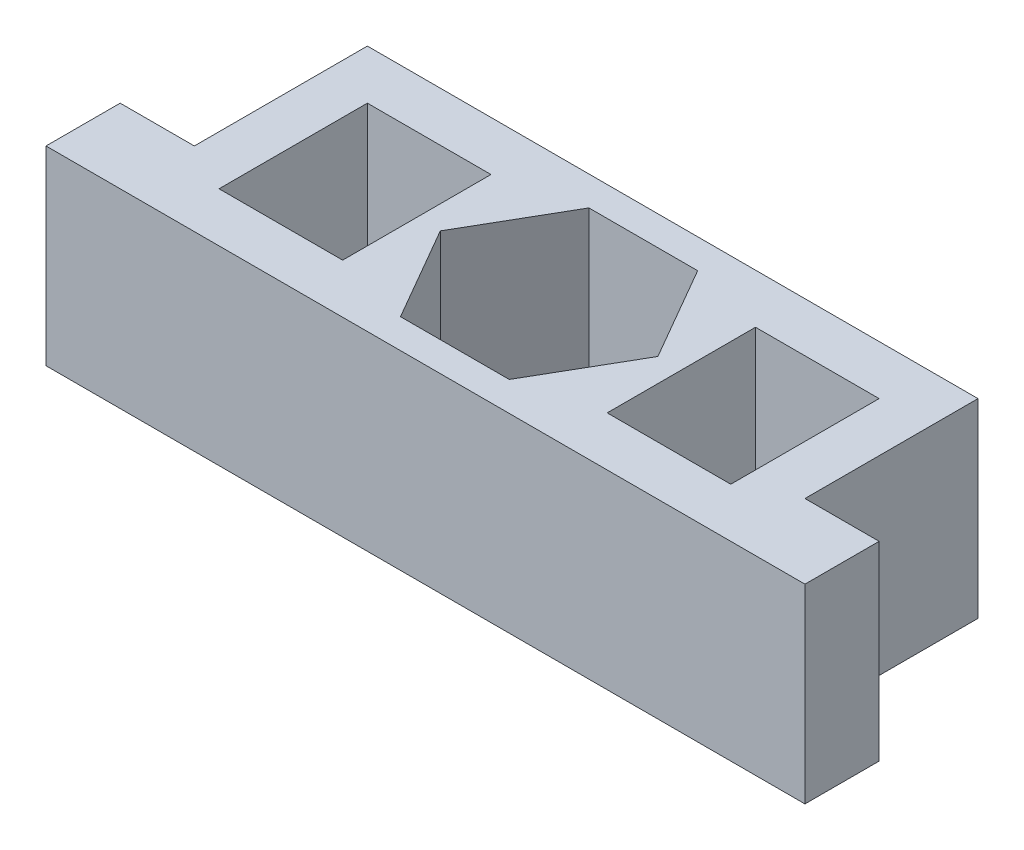
from build123d import *

# Parameters (mm, degrees)
SKETCH1_W           = 24.7
SKETCH1_H           = 7.7
BOSS_EXTRUDE1_DEPTH = 10
CUT_EXTRUDE1_DEPTH  = 10
SKETCH3_W           = 5
SKETCH3_H           = 6
CUT_EXTRUDE2_DEPTH  = 10
SKETCH4_W           = 3
SKETCH4_H           = 7.7
BOSS_EXTRUDE2_DEPTH = 3


with BuildPart() as part:
    # Sketch1 → Boss-Extrude1 (new body)
    with BuildSketch(Plane.XY):
        Rectangle(SKETCH1_W, SKETCH1_H)
    extrude(amount=BOSS_EXTRUDE1_DEPTH)

    # Sketch2 → Cut-Extrude1 (cut)
    with BuildSketch(Plane.XZ.offset(3.85)):
        Polygon((4.4, 5), (2.2, 8.810511777), (-2.2, 8.810511777), (-4.4, 5), (-2.2, 1.189488223), (2.2, 1.189488223), align=None)
    extrude(amount=-CUT_EXTRUDE1_DEPTH, mode=Mode.SUBTRACT)

    # Sketch3 → Cut-Extrude2 (cut)
    with BuildSketch(Plane(origin=(0, 3.85, 0), x_dir=(1, 0, 0), z_dir=(0, 1, 0))):
        with Locations((-7.85, -5)):
            Rectangle(SKETCH3_W, SKETCH3_H)
    cut_extrude2 = extrude(amount=-CUT_EXTRUDE2_DEPTH, mode=Mode.SUBTRACT)

    # Mirror1: Cut-Extrude2 across plane
    add(cut_extrude2.mirror(Plane(origin=(0, 0, 0), x_dir=(0, 0, 1), z_dir=(1, 0, 0))), mode=Mode.SUBTRACT)

    # Sketch4 → Boss-Extrude2 (add)
    with BuildSketch(Plane(origin=(12.35, 0, 0), x_dir=(0, 0, -1), z_dir=(1, 0, 0))):
        with Locations((-8.5, 0)):
            Rectangle(SKETCH4_W, SKETCH4_H)
    boss_extrude2 = extrude(amount=BOSS_EXTRUDE2_DEPTH)

    # Mirror2: Boss-Extrude2 across plane
    add(boss_extrude2.mirror(Plane(origin=(0, 0, 0), x_dir=(0, 0, 1), z_dir=(1, 0, 0))))


solid = part.part
